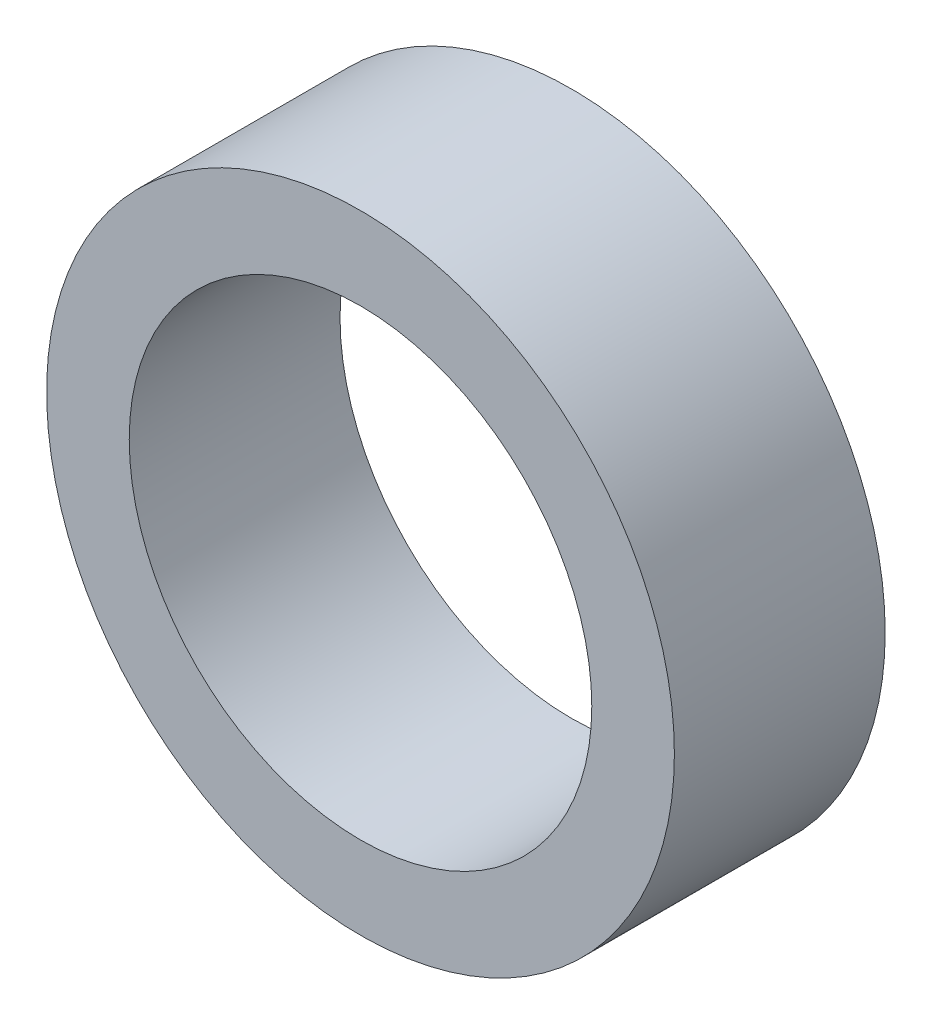
from build123d import *

# Parameters (mm, degrees)
SKETCH1_R           = 4.826
SKETCH1_R_2         = 3.556
BOSS_EXTRUDE1_DEPTH = 3.24104


with BuildPart() as part:
    # Sketch1 → Boss-Extrude1 (new body)
    with BuildSketch(Plane.XY):
        Circle(SKETCH1_R)
        Circle(SKETCH1_R_2, mode=Mode.SUBTRACT)
    extrude(amount=BOSS_EXTRUDE1_DEPTH)


solid = part.part
